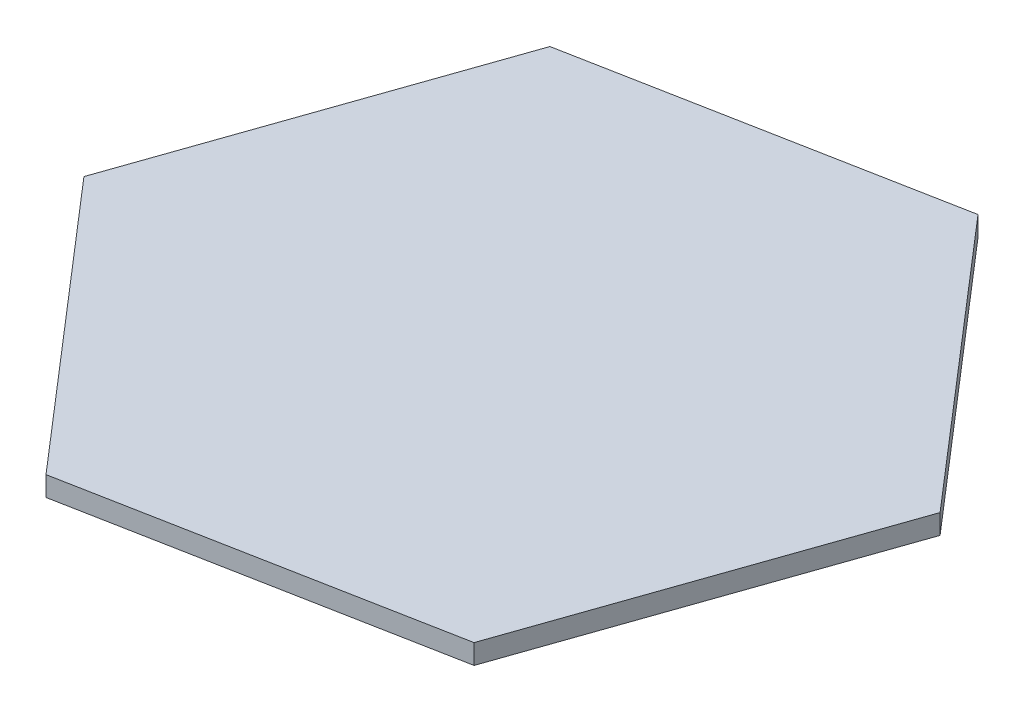
from build123d import *

# Parameters (mm, degrees)
BOSS_EXTRUDE2_DEPTH = 10


with BuildPart() as part:
    # Sketch1 → Boss-Extrude2 (new body)
    with BuildSketch(Plane(origin=(0, 0, 0), x_dir=(1, 0, 0), z_dir=(0, 1, 0))):
        Polygon((120.714393603, -139.859206622), (181.47882269, 34.612128152), (60.764429086, 174.471334774), (-120.714393603, 139.859206622), (-181.47882269, -34.612128152), (-60.764429086, -174.471334774), align=None)
    extrude(amount=BOSS_EXTRUDE2_DEPTH)


solid = part.part
